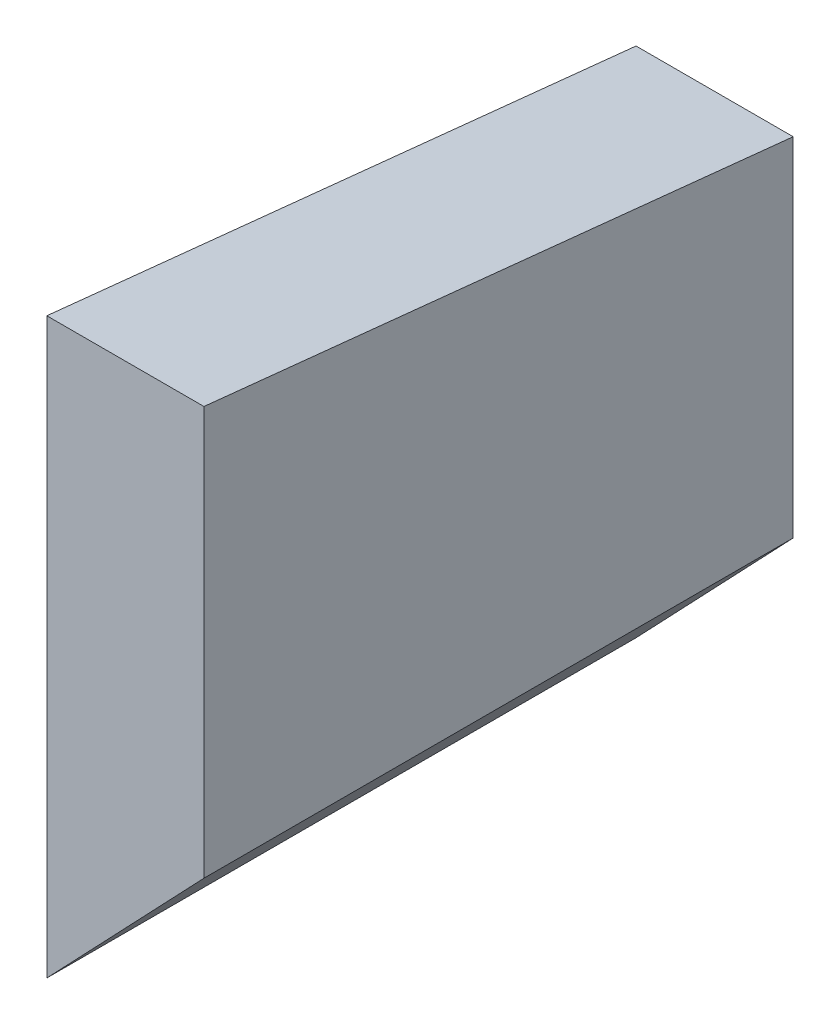
from build123d import *

# Parameters (mm, degrees)
ESQUISSE1_W             = 5.08
ESQUISSE1_H             = 19.05
BOSS_EXTRU_1_DEPTH      = 20.828
ENL_V_MAT_EXTRU_1_DEPTH = 6.08
ENL_V_MAT_EXTRU_2_DEPTH = 20.05


with BuildPart() as part:
    # Esquisse1 → Boss.-Extru.1 (new body)
    with BuildSketch(Plane(origin=(0, 0, 0), x_dir=(1, 0, 0), z_dir=(0, 1, 0))):
        with Locations((0, -9.525)):
            Rectangle(ESQUISSE1_W, ESQUISSE1_H)
    extrude(amount=-BOSS_EXTRU_1_DEPTH)

    # Esquisse2 → Enlèv. mat.-Extru.1 (cut, through all)
    with BuildSketch(Plane(origin=(2.54, 0, 0), x_dir=(0, 0, -1), z_dir=(1, 0, 0))):
        Polygon((0, -1.971986417), (-19.05, 0), (0, 0), align=None)
    extrude(amount=-ENL_V_MAT_EXTRU_1_DEPTH, mode=Mode.SUBTRACT)

    # Esquisse3 → Enlèv. mat.-Extru.2 (cut, through all)
    with BuildSketch(Plane.XY.offset(19.05)):
        Polygon((-2.54, -20.828), (-2.54, -18.542), (2.54, -13.208), (2.54, -20.828), align=None)
    extrude(amount=-ENL_V_MAT_EXTRU_2_DEPTH, mode=Mode.SUBTRACT)


solid = part.part
